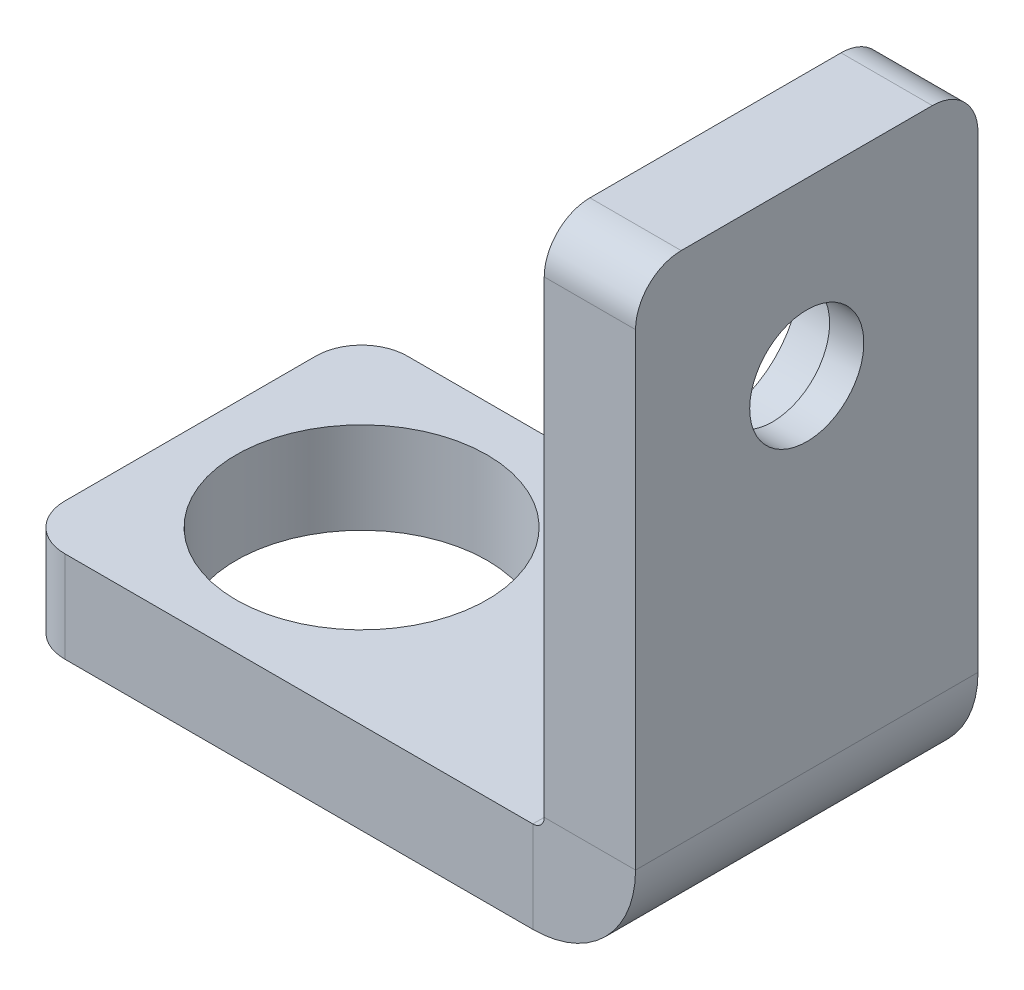
from build123d import *

# Parameters (mm, degrees)
SKETCH5_W          = 15
SKETCH5_H          = 4
SKETCH6_R          = 5.5
CUT_EXTRUDE1_DEPTH = 5
SKETCH7_R          = 2.5
CUT_EXTRUDE2_DEPTH = 5
FILLET1_R          = 2
SKETCH9_R          = 3.7
CUT_EXTRUDE3_DEPTH = 2.5


with BuildPart() as part:
    # Sweep1: sweep along a path in Sketch2
    with BuildLine(Plane.XY) as sweep1_path:
        Line((-25, 0), (-2.5, 0))
        ThreePointArc((-2.5, 0), (-0.732233047, 0.732233047), (0, 2.5))
        Line((0, 2.5), (0, 25))
    # Sketch5 → Sweep1 (sweep)
    with BuildSketch(Plane(origin=(-25, 0, 0), x_dir=(0, 0, -1), z_dir=(1, 0, 0))):
        Rectangle(SKETCH5_W, SKETCH5_H)
    sweep(path=sweep1_path.line)

    # Sketch6 → Cut-Extrude1 (cut, through all)
    with BuildSketch(Plane(origin=(0, 2, 0), x_dir=(1, 0, 0), z_dir=(0, 1, 0))):
        with Locations((-17.5, 0)):
            Circle(SKETCH6_R)
    extrude(amount=-CUT_EXTRUDE1_DEPTH, mode=Mode.SUBTRACT)

    # Sketch7 → Cut-Extrude2 (cut, through all)
    with BuildSketch(Plane.ZY.offset(2)):
        with Locations((0, 17.5)):
            Circle(SKETCH7_R)
    extrude(amount=-CUT_EXTRUDE2_DEPTH, mode=Mode.SUBTRACT)

    # Fillet1
    fillet1_edges = [part.edges().sort_by_distance(p)[0] for p in [
        (-25, 0, 7.5),
        (0, 25, -7.5),
        (0, 25, 7.5),
        (-25, 0, -7.5),
    ]]
    fillet(fillet1_edges, radius=FILLET1_R)

    # Sketch9 → Cut-Extrude3 (cut)
    with BuildSketch(Plane.ZY.offset(2)):
        with Locations((0, 17.5)):
            Circle(SKETCH9_R)
    extrude(amount=-CUT_EXTRUDE3_DEPTH, mode=Mode.SUBTRACT)


solid = part.part
